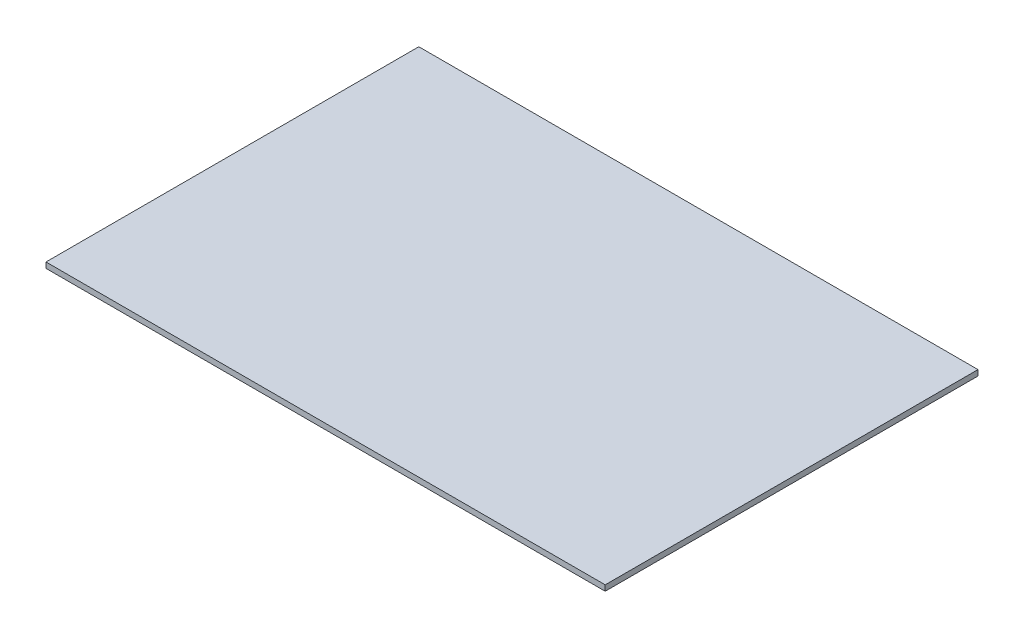
from build123d import *

# Parameters (mm, degrees)
SKETCH1_W           = 300
SKETCH1_H           = 200
BOSS_EXTRUDE1_DEPTH = 3


with BuildPart() as part:
    # Sketch1 → Boss-Extrude1 (new body)
    with BuildSketch(Plane(origin=(0, 0, 0), x_dir=(1, 0, 0), z_dir=(0, 1, 0))):
        Rectangle(SKETCH1_W, SKETCH1_H)
    extrude(amount=BOSS_EXTRUDE1_DEPTH)


solid = part.part
